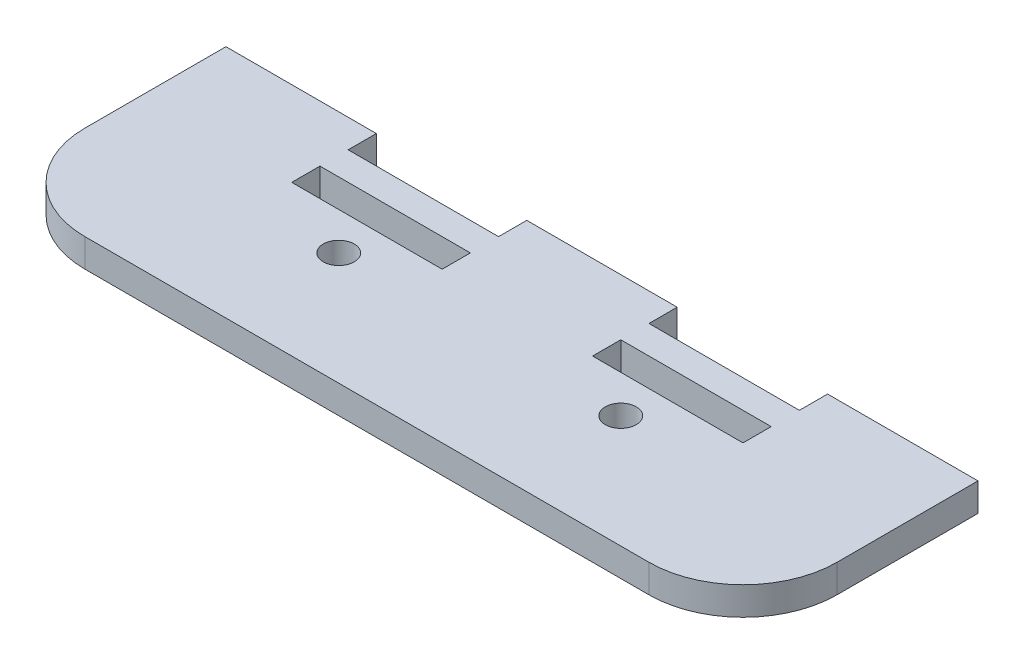
from build123d import *

# Parameters (mm, degrees)
SKETCH1_R           = 1.65
SKETCH1_W           = 16
SKETCH1_H           = 3
BOSS_EXTRUDE1_DEPTH = 3


with BuildPart() as part:
    # Sketch1 → Boss-Extrude1 (new body)
    with BuildSketch(Plane(origin=(0, 0, 0), x_dir=(1, 0, 0), z_dir=(0, 1, 0))):
        with BuildLine():
            Line((30, -12.5), (-30, -12.5))
            ThreePointArc((-30, -12.5), (-37.071067812, -9.571067812), (-40, -2.5))
            Line((-40, -2.5), (-40, 12.5))
            Line((-40, 12.5), (-24, 12.5))
            Line((-24, 12.5), (-24, 9.5))
            Line((-24, 9.5), (-8, 9.5))
            Line((-8, 9.5), (-8, 12.5))
            Line((-8, 12.5), (8, 12.5))
            Line((8, 12.5), (8, 9.5))
            Line((8, 9.5), (24, 9.5))
            Line((24, 9.5), (24, 12.5))
            Line((24, 12.5), (40, 12.5))
            Line((40, 12.5), (40, -2.5))
            ThreePointArc((40, -2.5), (37.071067812, -9.571067812), (30, -12.5))
        make_face()
        with Locations((-15, -0.5)):
            Circle(SKETCH1_R, mode=Mode.SUBTRACT)
        with Locations((15, -0.5)):
            Circle(SKETCH1_R, mode=Mode.SUBTRACT)
        with Locations((-16, 5)):
            Rectangle(SKETCH1_W, SKETCH1_H, mode=Mode.SUBTRACT)
        with Locations((16, 5)):
            Rectangle(SKETCH1_W, SKETCH1_H, mode=Mode.SUBTRACT)
    extrude(amount=BOSS_EXTRUDE1_DEPTH)


solid = part.part
